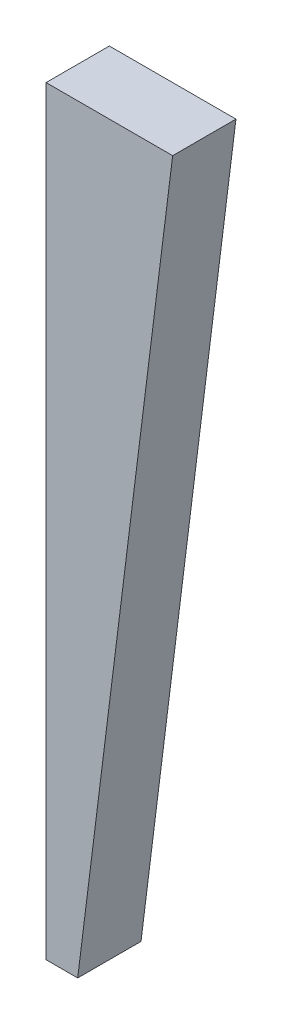
from build123d import *

# Parameters (mm, degrees)
BOSS_EXTRUDE1_DEPTH = 6.35


with BuildPart() as part:
    # Sketch1 → Boss-Extrude1 (new body)
    with BuildSketch(Plane.XY):
        Polygon((0, 0), (12.7, 0), (3.175, -76.2), (0, -76.2), align=None)
    extrude(amount=BOSS_EXTRUDE1_DEPTH)


solid = part.part
